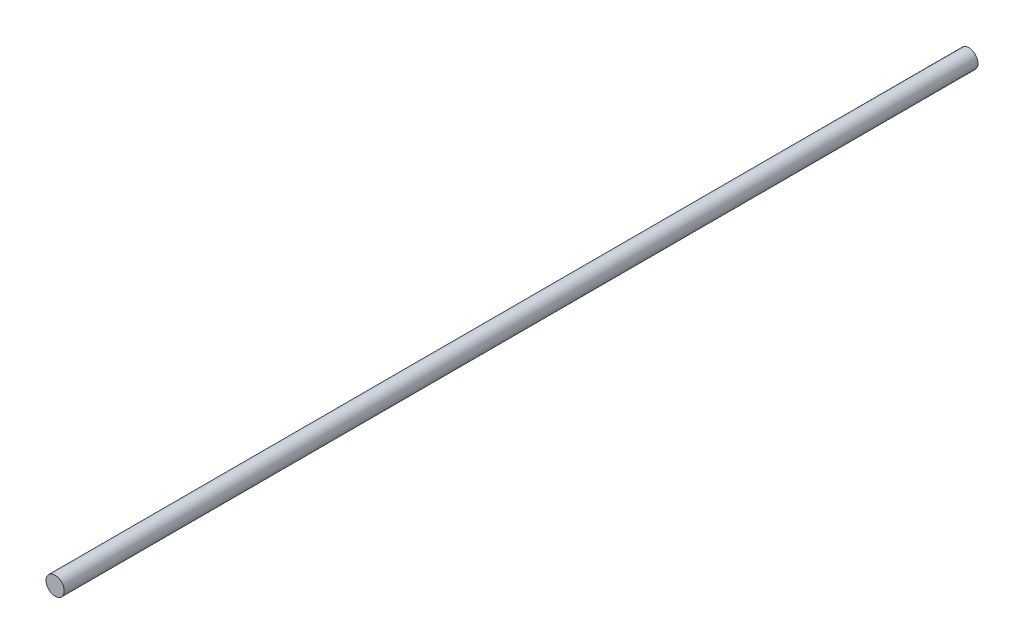
from build123d import *

# Parameters (mm, degrees)
SKETCH1_R      = 4
ROD_BODY_DEPTH = 400


with BuildPart() as part:
    # Sketch1 → rod body (new body)
    with BuildSketch(Plane.XY):
        Circle(SKETCH1_R)
    extrude(amount=ROD_BODY_DEPTH)


solid = part.part
